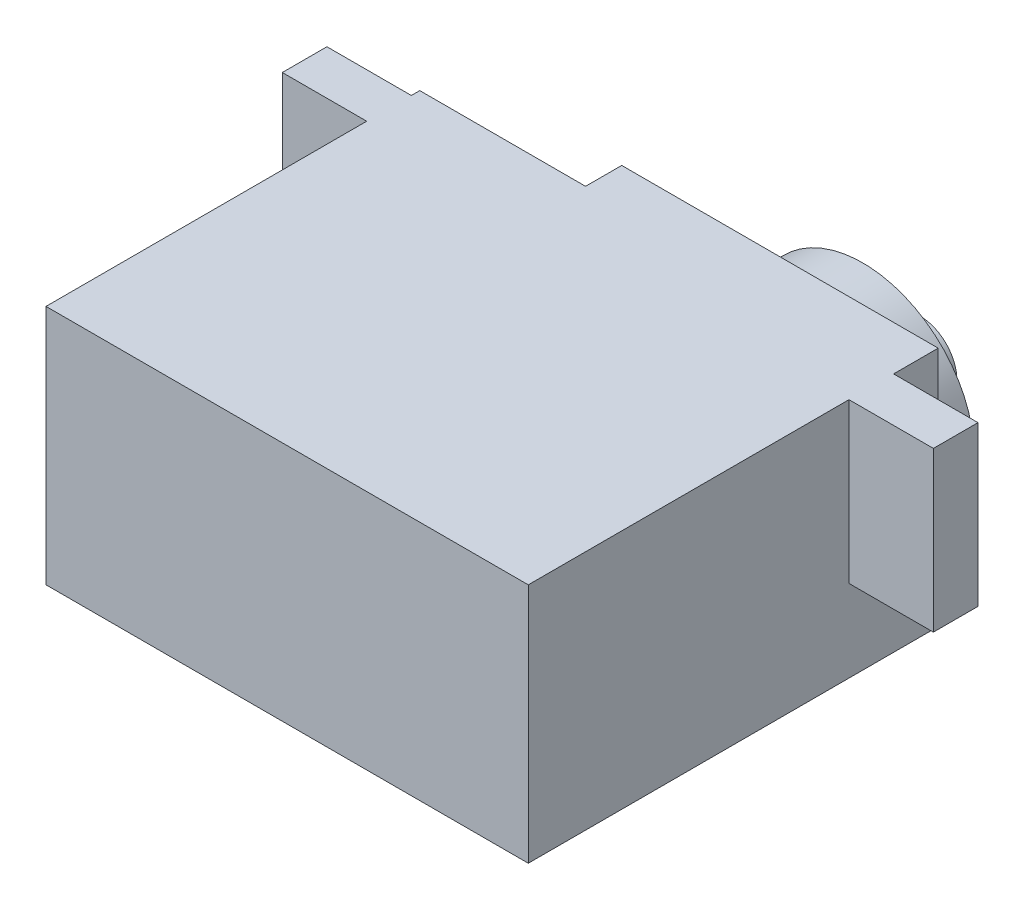
from build123d import *

# Parameters (mm, degrees)
SKETCH1_W           = 40
SKETCH1_H           = 34
BOSS_EXTRUDE1_DEPTH = 20
SKETCH2_W           = 13.75
SKETCH2_H           = 3
CUT_EXTRUDE1_DEPTH  = 21
SKETCH3_R           = 9.25
SKETCH3_R_2         = 3.05
BOSS_EXTRUDE2_DEPTH = 3.75
SKETCH4_W           = 7
SKETCH4_H           = 3.7
BOSS_EXTRUDE3_DEPTH = 13.2
SKETCH8_R           = 3.05
BOSS_EXTRUDE5_DEPTH = 8.5


with BuildPart() as part:
    # Sketch1 → Boss-Extrude1 (new body)
    with BuildSketch(Plane(origin=(0, 0, 0), x_dir=(1, 0, 0), z_dir=(0, 1, 0))):
        with Locations((-0.96024493, -2.107462687)):
            Rectangle(SKETCH1_W, SKETCH1_H)
    extrude(amount=BOSS_EXTRUDE1_DEPTH)

    # Sketch2 → Cut-Extrude1 (cut, through all)
    with BuildSketch(Plane(origin=(0, 20, 0), x_dir=(1, 0, 0), z_dir=(0, 1, 0))):
        with Locations((-14.08524493, 13.392537313)):
            Rectangle(SKETCH2_W, SKETCH2_H)
    extrude(amount=-CUT_EXTRUDE1_DEPTH, mode=Mode.SUBTRACT)

    # Sketch3 → Boss-Extrude2 (add)
    with BuildSketch(Plane(origin=(0, 0, -14.892537313), x_dir=(-1, 0, 0), z_dir=(0, 0, -1))):
        with Locations((-9.03975507, 10)):
            Circle(SKETCH3_R)
        with Locations((-9.03975507, 10)):
            Circle(SKETCH3_R_2, mode=Mode.SUBTRACT)
    extrude(amount=BOSS_EXTRUDE2_DEPTH)

    # Sketch4 → Boss-Extrude3 (add)
    with BuildSketch(Plane(origin=(0, 20, 0), x_dir=(1, 0, 0), z_dir=(0, 1, 0))):
        with Locations((-24.46024493, 9.342537313)):
            Rectangle(SKETCH4_W, SKETCH4_H)
        with Locations((22.53975507, 9.342537313)):
            Rectangle(SKETCH4_W, SKETCH4_H)
    extrude(amount=-BOSS_EXTRUDE3_DEPTH)

    # Sketch8 → Boss-Extrude5 (add)
    with BuildSketch(Plane(origin=(0, 0, -14.892537313), x_dir=(-1, 0, 0), z_dir=(0, 0, -1))):
        with Locations((-9.03975507, 10)):
            Circle(SKETCH8_R)
    extrude(amount=BOSS_EXTRUDE5_DEPTH)


solid = part.part
